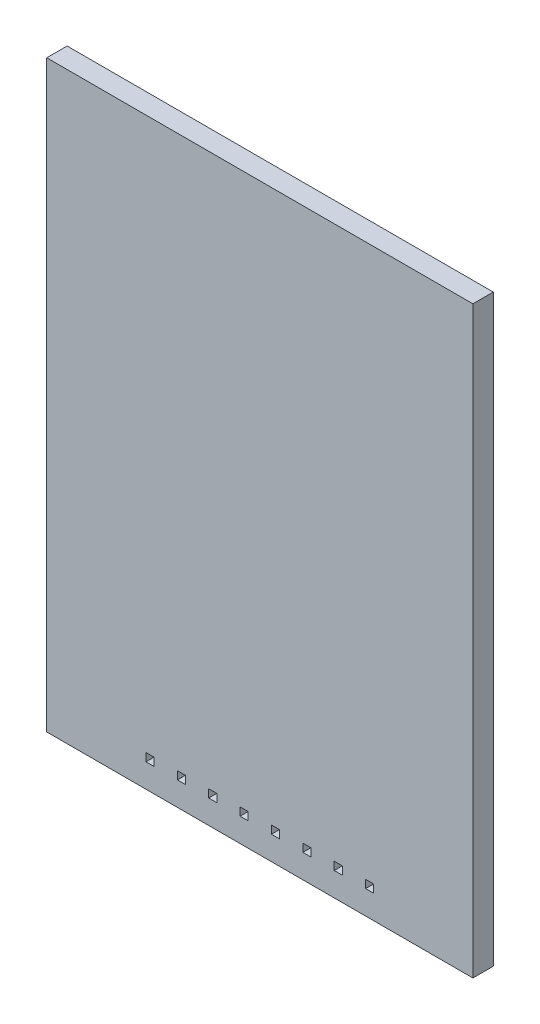
from build123d import *

# Parameters (mm, degrees)
SKETCH1_W               = 34.5
SKETCH1_H               = 47.27
BOSS_EXTRUDE1_DEPTH     = 1.65
BOSS_EXTRUDE2_START     = -3.05
SKETCH2_W               = 0.65
SKETCH2_H               = 0.65
BOSS_EXTRUDE2_DEPTH     = 11.55
CUT_EXTRUDE1_START      = -4.05
SKETCH2_2_W             = 0.65
SKETCH2_2_H             = 0.65
CUT_EXTRUDE1_DEPTH      = 13.55
LPATTERN1_COUNT         = 4
LPATTERN1_PITCH         = 2.54
MIRROR1_START           = -4.05
MIRROR1_COPY_1_SKETCH_W = 0.65
MIRROR1_COPY_1_SKETCH_H = 0.65
MIRROR1_COPY_1_DEPTH    = 13.55
MIRROR1_COPY_2_SKETCH_W = 0.65
MIRROR1_COPY_2_SKETCH_H = 0.65
MIRROR1_COPY_2_DEPTH    = 13.55
MIRROR1_COPY_3_SKETCH_W = 0.65
MIRROR1_COPY_3_SKETCH_H = 0.65
MIRROR1_COPY_3_DEPTH    = 13.55
MIRROR1_COPY_4_SKETCH_W = 0.65
MIRROR1_COPY_4_SKETCH_H = 0.65
MIRROR1_COPY_4_DEPTH    = 13.55


with BuildPart() as part:
    # Sketch1 → Boss-Extrude1 (new body)
    with BuildSketch(Plane.XY):
        Rectangle(SKETCH1_W, SKETCH1_H)
    extrude(amount=BOSS_EXTRUDE1_DEPTH)

    # Sketch2 → Boss-Extrude2 (add)
    with BuildSketch(Plane(origin=(0, 0, 0), x_dir=(-1, 0, 0), z_dir=(0, 0, -1)).offset(BOSS_EXTRUDE2_START)):
        with Locations((-1.27, -21.385)):
            Rectangle(SKETCH2_W, SKETCH2_H)
    boss_extrude2 = extrude(amount=BOSS_EXTRUDE2_DEPTH)

    # Sketch2_2 → Cut-Extrude1 (cut)
    with BuildSketch(Plane(origin=(0, 0, 0), x_dir=(-1, 0, 0), z_dir=(0, 0, -1)).offset(CUT_EXTRUDE1_START)):
        with Locations((-1.27, -21.385)):
            Rectangle(SKETCH2_2_W, SKETCH2_2_H)
    cut_extrude1 = extrude(amount=CUT_EXTRUDE1_DEPTH, mode=Mode.SUBTRACT)

    # LPattern1: Cut-Extrude1 ×4
    with Locations(*[(i * LPATTERN1_PITCH, 0, 0) for i in range(1, LPATTERN1_COUNT)]):
        add(cut_extrude1, mode=Mode.SUBTRACT)

    # Mirror1: Boss-Extrude2 across plane
    add(boss_extrude2.mirror(Plane(origin=(0, 0, 0), x_dir=(0, 0, 1), z_dir=(1, 0, 0))))

    # Mirror1 copy 1 sketch → Mirror1 copy 1 (cut)
    with BuildSketch(Plane(origin=(-2.54, 0, 0), x_dir=(1, 0, 0), z_dir=(0, 0, -1)).offset(MIRROR1_START)):
        with Locations((-1.27, 21.385)):
            Rectangle(MIRROR1_COPY_1_SKETCH_W, MIRROR1_COPY_1_SKETCH_H)
    extrude(amount=MIRROR1_COPY_1_DEPTH, mode=Mode.SUBTRACT)

    # Mirror1 copy 2 sketch → Mirror1 copy 2 (cut)
    with BuildSketch(Plane(origin=(-5.08, 0, 0), x_dir=(1, 0, 0), z_dir=(0, 0, -1)).offset(MIRROR1_START)):
        with Locations((-1.27, 21.385)):
            Rectangle(MIRROR1_COPY_2_SKETCH_W, MIRROR1_COPY_2_SKETCH_H)
    extrude(amount=MIRROR1_COPY_2_DEPTH, mode=Mode.SUBTRACT)

    # Mirror1 copy 3 sketch → Mirror1 copy 3 (cut)
    with BuildSketch(Plane(origin=(-7.62, 0, 0), x_dir=(1, 0, 0), z_dir=(0, 0, -1)).offset(MIRROR1_START)):
        with Locations((-1.27, 21.385)):
            Rectangle(MIRROR1_COPY_3_SKETCH_W, MIRROR1_COPY_3_SKETCH_H)
    extrude(amount=MIRROR1_COPY_3_DEPTH, mode=Mode.SUBTRACT)

    # Mirror1 copy 4 sketch → Mirror1 copy 4 (cut)
    with BuildSketch(Plane(origin=(0, 0, 0), x_dir=(1, 0, 0), z_dir=(0, 0, -1)).offset(MIRROR1_START)):
        with Locations((-1.27, 21.385)):
            Rectangle(MIRROR1_COPY_4_SKETCH_W, MIRROR1_COPY_4_SKETCH_H)
    extrude(amount=MIRROR1_COPY_4_DEPTH, mode=Mode.SUBTRACT)


solid = part.part
